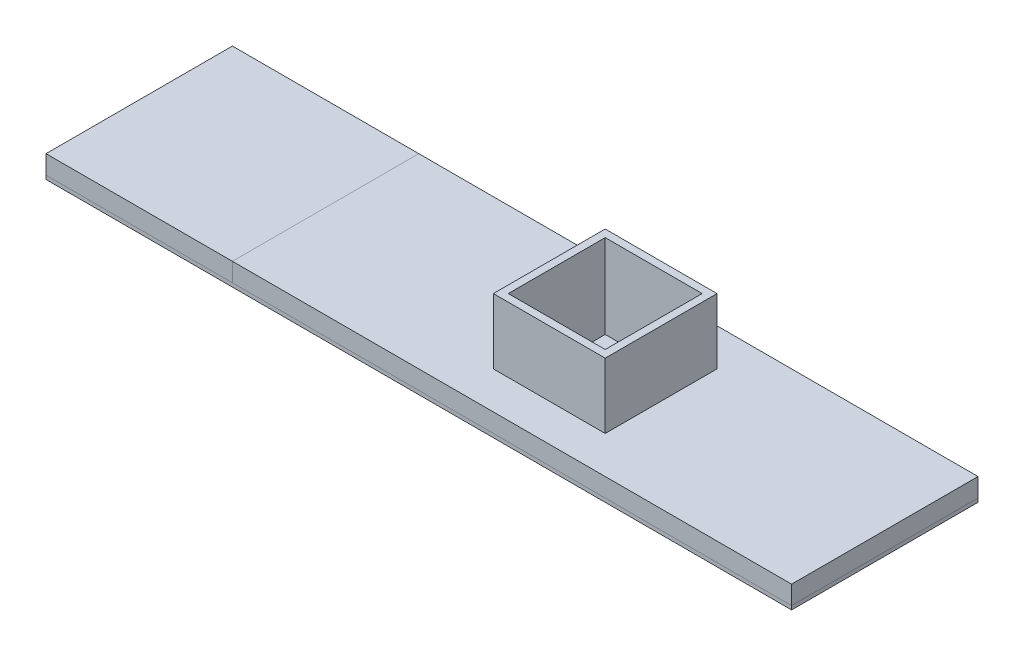
from build123d import *

# Parameters (mm, degrees)
SKETCH1_W           = 75
SKETCH1_H           = 25
SLIDE_DEPTH         = 1.25
SKETCH4_W           = 25
SKETCH4_H           = 25
LABEL_DEPTH         = 1.25
SKETCH5_W           = 15
SKETCH5_H           = 15
SKETCH5_W_2         = 13
SKETCH5_H_2         = 13
BOSS_EXTRUDE1_DEPTH = 10
SKETCH6_W           = 13
SKETCH6_H           = 13
CUT_EXTRUDE1_DEPTH  = 2.5
SKETCH7_W           = 25
SKETCH7_H           = 0.5
BOSS_EXTRUDE2_DEPTH = 100


with BuildPart() as part:
    # Sketch1 → Slide (new body, symmetric)
    with BuildSketch(Plane(origin=(0, 0, 0), x_dir=(1, 0, 0), z_dir=(0, 1, 0))):
        Rectangle(SKETCH1_W, SKETCH1_H)
    extrude(amount=SLIDE_DEPTH, both=True)

    # Sketch5 → Boss-Extrude1 (add)
    with BuildSketch(Plane(origin=(0, 0, 0), x_dir=(1, 0, 0), z_dir=(0, 1, 0))):
        Rectangle(SKETCH5_W, SKETCH5_H)
        Rectangle(SKETCH5_W_2, SKETCH5_H_2, mode=Mode.SUBTRACT)
    extrude(amount=BOSS_EXTRUDE1_DEPTH)

    # Sketch6 → Cut-Extrude1 (cut)
    with BuildSketch(Plane(origin=(0, 1.25, 0), x_dir=(1, 0, 0), z_dir=(0, 1, 0))):
        Rectangle(SKETCH6_W, SKETCH6_H)
    extrude(amount=-CUT_EXTRUDE1_DEPTH, mode=Mode.SUBTRACT)


with BuildPart() as body_2:
    # Sketch4 → Label (new body, symmetric)
    with BuildSketch(Plane(origin=(0, 0, 0), x_dir=(1, 0, 0), z_dir=(0, 1, 0))):
        with Locations((-50, 0)):
            Rectangle(SKETCH4_W, SKETCH4_H)
    extrude(amount=LABEL_DEPTH, both=True)


with BuildPart() as body_3:
    # Sketch7 → Boss-Extrude2 (new body)
    with BuildSketch(Plane.ZY.offset(62.5)):
        with Locations((0, -1.5)):
            Rectangle(SKETCH7_W, SKETCH7_H)
    extrude(amount=-BOSS_EXTRUDE2_DEPTH)


solid = Compound([part.part, body_2.part, body_3.part])
